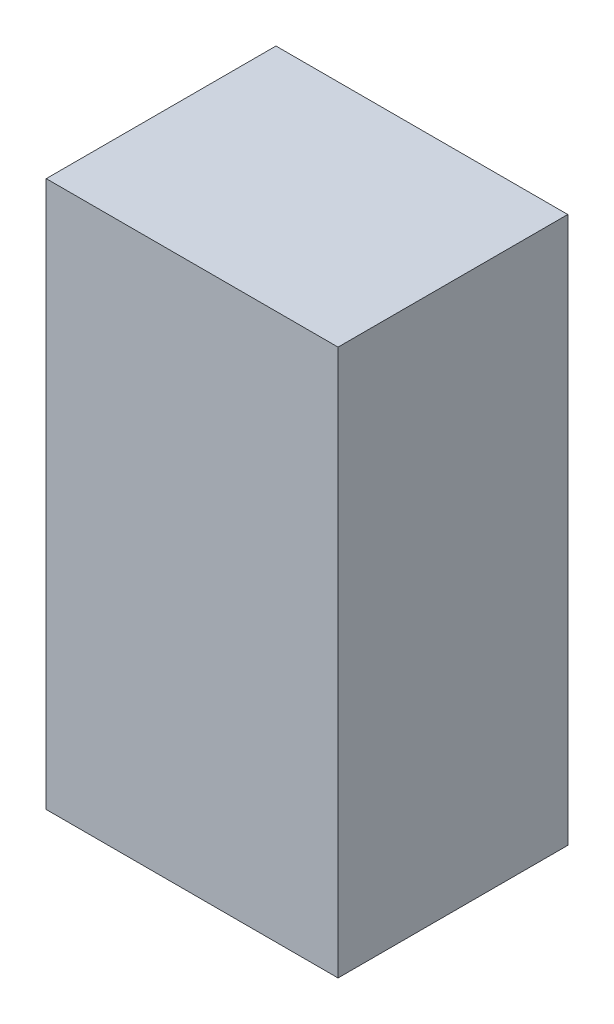
from build123d import *

# Parameters (mm, degrees)
SKETCH1_W           = 596.9
SKETCH1_H           = 469.9
BOSS_EXTRUDE1_DEPTH = 1117.6


with BuildPart() as part:
    # Sketch1 → Boss-Extrude1 (new body)
    with BuildSketch(Plane(origin=(0, 0, 0), x_dir=(1, 0, 0), z_dir=(0, 1, 0))):
        Rectangle(SKETCH1_W, SKETCH1_H)
    extrude(amount=BOSS_EXTRUDE1_DEPTH)


solid = part.part
